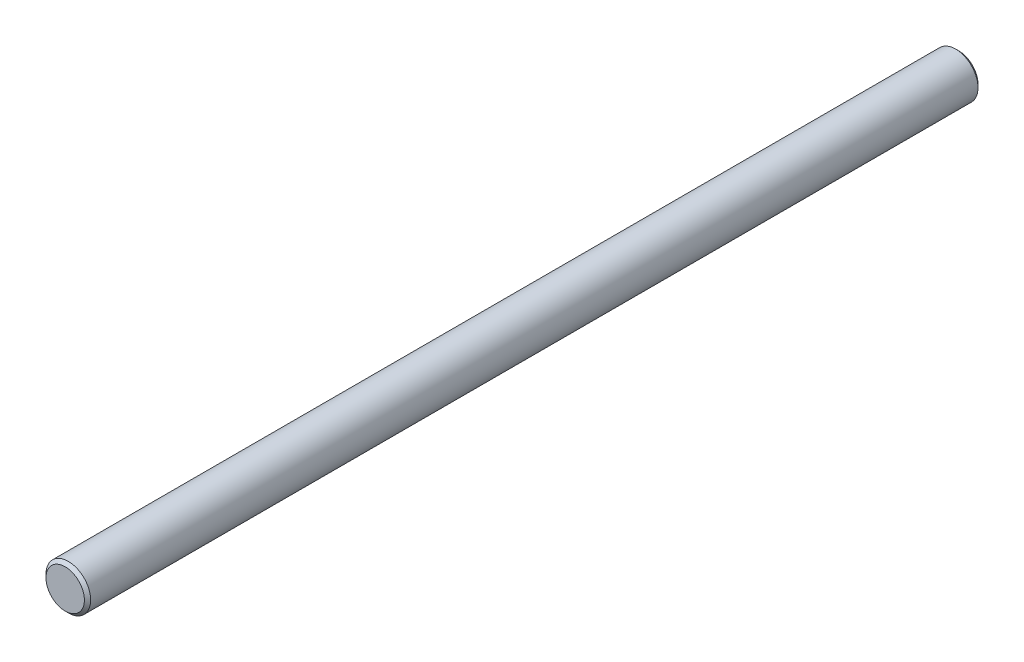
from build123d import *

# Parameters (mm, degrees)
SKETCH3_R                = 2.5
BOSS_EXTRUDE1_DEPTH      = 50
BOSS_EXTRUDE1_DEPTH_BACK = 50
CHAMFER1_SIZE            = 0.35


with BuildPart() as part:
    # Sketch3 → Boss-Extrude1 (new body, two sides)
    with BuildSketch(Plane.XY) as boss_extrude1_sk:
        Circle(SKETCH3_R)
    extrude(amount=BOSS_EXTRUDE1_DEPTH)
    extrude(boss_extrude1_sk.sketch, amount=-BOSS_EXTRUDE1_DEPTH_BACK)

    # Chamfer1
    chamfer1_edges = [part.edges().sort_by_distance(p)[0] for p in [
        (-2.5, 0, -50),
        (-2.5, 0, 50),
    ]]
    chamfer(chamfer1_edges, length=CHAMFER1_SIZE)


solid = part.part
